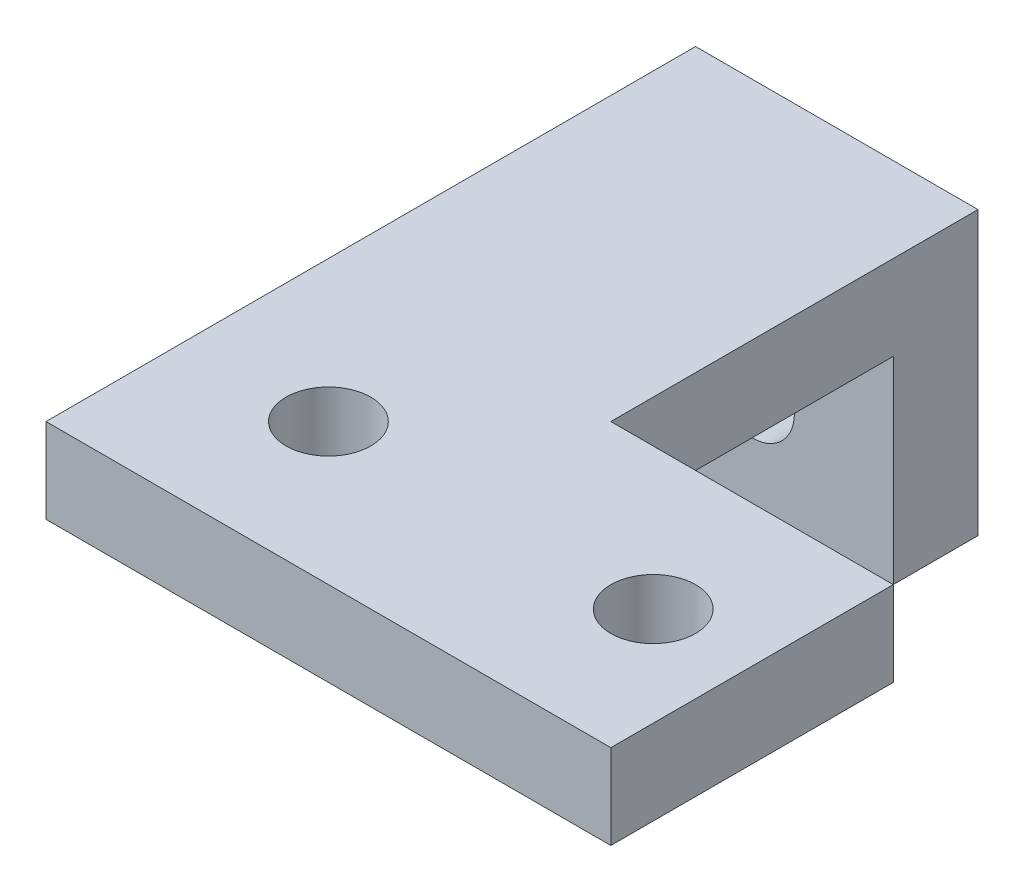
from build123d import *

# Parameters (mm, degrees)
BOSS_EXTRUDE1_DEPTH = 3
SKETCH2_W           = 10
SKETCH2_H           = 3
BOSS_EXTRUDE2_DEPTH = 10
CUT_EXTRUDE1_REACH  = 12
SKETCH3_R           = 1.5
CUT_EXTRUDE2_REACH  = 25
SKETCH4_R           = 1.5


with BuildPart() as part:
    # Sketch1 → Boss-Extrude1 (new body)
    with BuildSketch(Plane(origin=(0, 0, 0), x_dir=(1, 0, 0), z_dir=(0, 1, 0))):
        Polygon((0, 0), (0, 10), (-10, 10), (-10, -10), (10, -10), (10, 0), align=None)
    extrude(amount=BOSS_EXTRUDE1_DEPTH)

    # Sketch2 → Boss-Extrude2 (add)
    with BuildSketch(Plane(origin=(0, 3, 0), x_dir=(1, 0, 0), z_dir=(0, 1, 0))):
        with Locations((-5, 11.5)):
            Rectangle(SKETCH2_W, SKETCH2_H)
    extrude(amount=-BOSS_EXTRUDE2_DEPTH)

    # Sketch3 → Cut-Extrude1 (cut, up to next)
    with BuildSketch(Plane(origin=(0, 3, 0), x_dir=(1, 0, 0), z_dir=(0, 1, 0)), mode=Mode.PRIVATE) as cut_extrude1_sk1:
        with Locations((-5, -5)):
            Circle(SKETCH3_R)
    cut_extrude1_tool1 = extrude(cut_extrude1_sk1.sketch, amount=-CUT_EXTRUDE1_REACH, mode=Mode.PRIVATE) & part.part
    add(cut_extrude1_tool1.solids().sort_by_distance((-5, 3, 5))[0], mode=Mode.SUBTRACT)
    # Sketch3 → Cut-Extrude1 (cut, up to next)
    with BuildSketch(Plane(origin=(0, 3, 0), x_dir=(1, 0, 0), z_dir=(0, 1, 0)), mode=Mode.PRIVATE) as cut_extrude1_sk2:
        with Locations((6.5, -5)):
            Circle(SKETCH3_R)
    cut_extrude1_tool2 = extrude(cut_extrude1_sk2.sketch, amount=-CUT_EXTRUDE1_REACH, mode=Mode.PRIVATE) & part.part
    add(cut_extrude1_tool2.solids().sort_by_distance((6.5, 3, 5))[0], mode=Mode.SUBTRACT)

    # Sketch4 → Cut-Extrude2 (cut, up to next)
    with BuildSketch(Plane(origin=(0, 0, -13), x_dir=(-1, 0, 0), z_dir=(0, 0, -1)), mode=Mode.PRIVATE) as cut_extrude2_sk1:
        with Locations((5, -3.5)):
            Circle(SKETCH4_R)
    cut_extrude2_tool1 = extrude(cut_extrude2_sk1.sketch, amount=-CUT_EXTRUDE2_REACH, mode=Mode.PRIVATE) & part.part
    add(cut_extrude2_tool1.solids().sort_by_distance((-5, -3.5, -13))[0], mode=Mode.SUBTRACT)


solid = part.part
